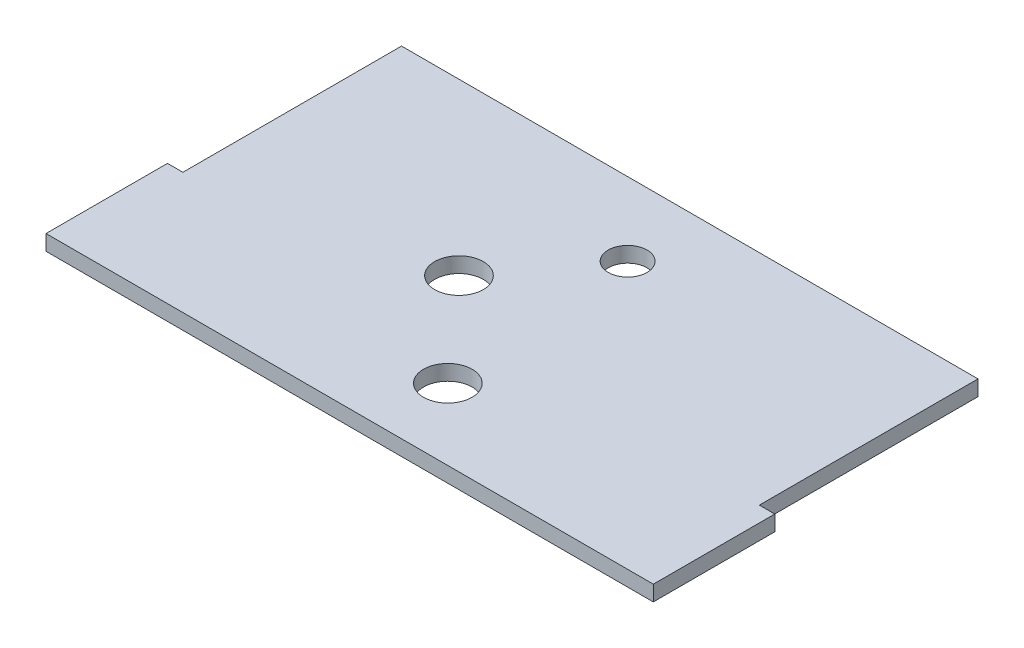
from build123d import *

# Parameters (mm, degrees)
SKETCH1_W                      = 125
SKETCH1_H                      = 70
BOSS_EXTRUDE1_DEPTH            = 3.175
F_10_0_10_DIAMETER_HOLE1_D     = 10
F_10_0_10_DIAMETER_HOLE1_DEPTH = 3.175
F_8_0_8_DIAMETER_HOLE1_D       = 8
F_8_0_8_DIAMETER_HOLE1_DEPTH   = 3.175
CUT_EXTRUDE1_DEPTH             = 4.175


with BuildPart() as part:
    # Sketch1 → Boss-Extrude1 (new body)
    with BuildSketch(Plane(origin=(0, 0, 0), x_dir=(1, 0, 0), z_dir=(0, 1, 0))):
        Rectangle(SKETCH1_W, SKETCH1_H)
    extrude(amount=BOSS_EXTRUDE1_DEPTH)

    # Ø10.0 (10) Diameter Hole1
    with Locations(Plane(origin=(0, 3.175, 0), x_dir=(1, 0, 0), z_dir=(0, 1, 0))):
        with Locations((-12.5, 0), (5.544081657, -20.339852315)):
            Hole(F_10_0_10_DIAMETER_HOLE1_D / 2, depth=F_10_0_10_DIAMETER_HOLE1_DEPTH)

    # Ø8.0 (8) Diameter Hole1
    with Locations(Plane(origin=(0, 3.175, 0), x_dir=(1, 0, 0), z_dir=(0, 1, 0))):
        with Locations((2.300160709, 19.912165142), (-12.5, 0)):
            Hole(F_8_0_8_DIAMETER_HOLE1_D / 2, depth=F_8_0_8_DIAMETER_HOLE1_DEPTH)

    # Sketch7 → Cut-Extrude1 (cut, through all)
    with BuildSketch(Plane(origin=(0, 3.175, 0), x_dir=(1, 0, 0), z_dir=(0, 1, 0))):
        Polygon((-62.5, 35), (-59.325, 35), (-59.325, 10), (-59.325, -10), (-62.5, -10), (-62.5, 10), align=None)
        Polygon((62.5, 35), (59.325, 35), (59.325, 10), (59.325, -10), (62.5, -10), (62.5, 10), align=None)
    extrude(amount=-CUT_EXTRUDE1_DEPTH, mode=Mode.SUBTRACT)


solid = part.part
